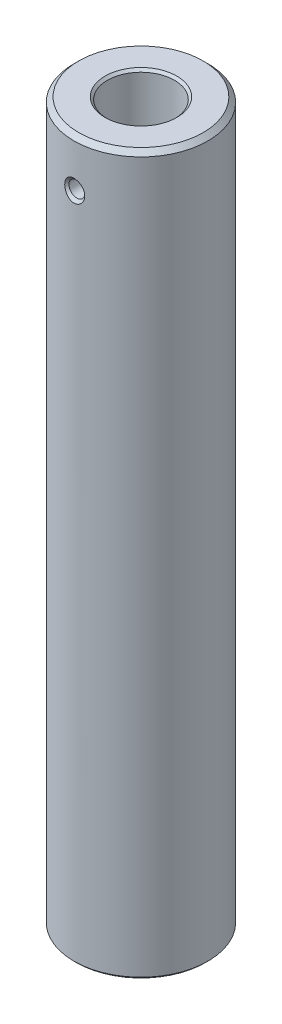
from build123d import *

# Parameters (mm, degrees)
ESQUISSE1_R                               = 14
BOSS_EXTRU_1_DEPTH                        = 150
CHANFREIN1_SIZE                           = 1
DIAM_TRE_DU_PER_AGE_14_0_14_1_D           = 14
DIAM_TRE_DU_PER_AGE_14_0_14_1_DEPTH       = 35
DIAM_TRE_DU_PER_AGE_14_0_14_1_CSINK_D     = 15
DIAM_TRE_DU_PER_AGE_14_0_14_1_CSINK_ANGLE = 90
DIAM_TRE_DU_PER_AGE_14_0_14_1_TIP         = 4.206024333
CHANFREIN2_SIZE                           = 0.5
TROU_TARAUD_M8X1_01_D                     = 7
TROU_TARAUD_M8X1_01_DEPTH                 = 25
TROU_TARAUD_M8X1_01_TIP                   = 2.103012167


with BuildPart() as part:
    # Esquisse1 → Boss.-Extru.1 (new body)
    with BuildSketch(Plane(origin=(0, 0, 0), x_dir=(1, 0, 0), z_dir=(0, 1, 0))):
        with Locations(Location((0, 0, 0), (0, 0, 270))):  # turned: the seam where the file's is
            Circle(ESQUISSE1_R)
    extrude(amount=BOSS_EXTRU_1_DEPTH)

    # Chanfrein1
    chanfrein1_edges = [part.edges().sort_by_distance(p)[0] for p in [
        (0, 150, -14),
    ]]
    chamfer(chanfrein1_edges, length=CHANFREIN1_SIZE)

    # Diamètre du perçage Ø14.0 (14)1
    with Locations(Plane(origin=(0, 150, 0), x_dir=(-1, 0, 0), z_dir=(0, 1, 0))):
        with Locations((0, 0)):
            CounterSinkHole(DIAM_TRE_DU_PER_AGE_14_0_14_1_D / 2, DIAM_TRE_DU_PER_AGE_14_0_14_1_CSINK_D / 2, depth=DIAM_TRE_DU_PER_AGE_14_0_14_1_DEPTH, counter_sink_angle=DIAM_TRE_DU_PER_AGE_14_0_14_1_CSINK_ANGLE)
            with Locations((0, 0, -(DIAM_TRE_DU_PER_AGE_14_0_14_1_DEPTH + DIAM_TRE_DU_PER_AGE_14_0_14_1_TIP / 2))):  # 118° drill point
                Cone(0, DIAM_TRE_DU_PER_AGE_14_0_14_1_D / 2, DIAM_TRE_DU_PER_AGE_14_0_14_1_TIP, mode=Mode.SUBTRACT)

    # Chanfrein2
    chanfrein2_edges = [part.edges().sort_by_distance(p)[0] for p in [
        (0, 0, -14),
    ]]
    chamfer(chanfrein2_edges, length=CHANFREIN2_SIZE)

    # Trou taraudé M8x1.01
    with Locations(Plane.XZ):
        with Locations((0, 0)):
            Hole(TROU_TARAUD_M8X1_01_D / 2, depth=TROU_TARAUD_M8X1_01_DEPTH)
            with Locations((0, 0, -(TROU_TARAUD_M8X1_01_DEPTH + TROU_TARAUD_M8X1_01_TIP / 2))):  # 118° drill point
                Cone(0, TROU_TARAUD_M8X1_01_D / 2, TROU_TARAUD_M8X1_01_TIP, mode=Mode.SUBTRACT)

    # Esquisse11 → Trou taraudé M42 (revolve, cut)
    with BuildSketch(Plane(origin=(0, 140, 0), x_dir=(0, 1, 0), z_dir=(1, 0, 0))):
        Polygon((0, 0), (0, 14), (2.25, 14), (1.65, 13.4), (1.65, 0), align=None)
    revolve(axis=Axis((0, 140, -6.35), (0, 0, 1)), mode=Mode.SUBTRACT)


solid = part.part
